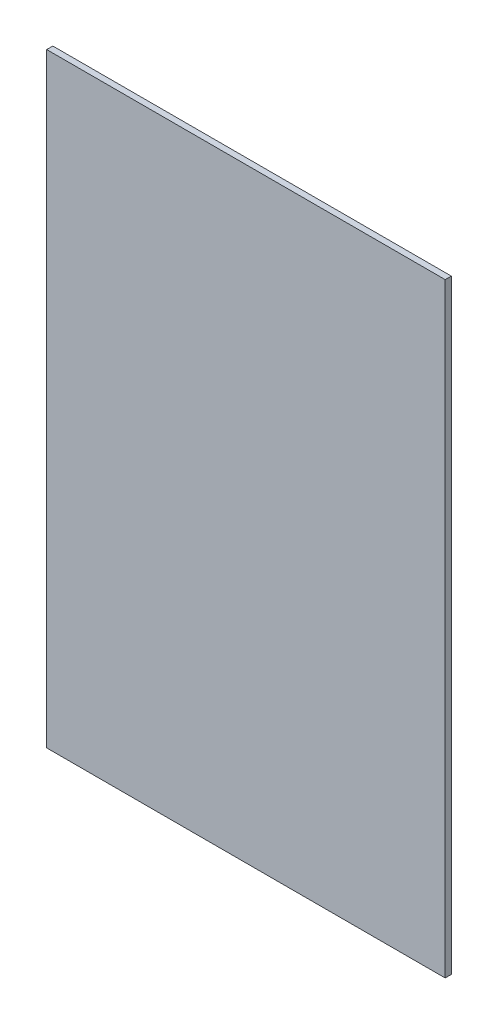
from build123d import *

# Parameters (mm, degrees)
SKETCH1_W      = 260
SKETCH1_H      = 394.6
EXTRUDE1_DEPTH = 4


with BuildPart() as part:
    # Sketch1 → Extrude1 (new body)
    with BuildSketch(Plane.XY):
        with Locations((0, -67.3)):
            Rectangle(SKETCH1_W, SKETCH1_H)
    extrude(amount=EXTRUDE1_DEPTH)


solid = part.part
